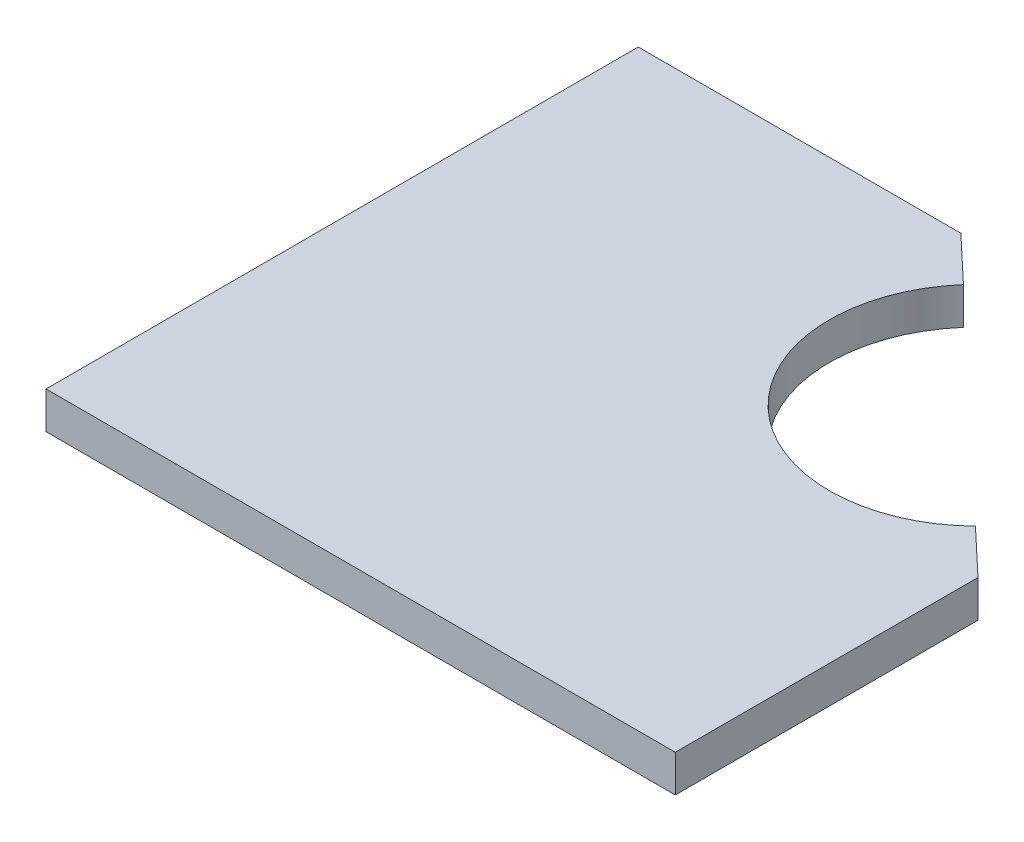
from build123d import *

# Parameters (mm, degrees)
BOSS_EXTRU_1_DEPTH = 5


with BuildPart() as part:
    # Esquisse1 → Boss.-Extru.1 (new body)
    with BuildSketch(Plane(origin=(0, 0, 0), x_dir=(1, 0, 0), z_dir=(0, 1, 0))):
        with BuildLine():
            Line((-42.5, 40), (1.075699519, 40))
            Line((1.075699519, 40), (7.256174968, 34.16461456))
            ThreePointArc((7.256174968, 34.16461456), (8.582181318, 6.457704827), (36.319524552, 6.724031969))
            Line((36.319524552, 6.724031969), (42.5, 0.88864653))
            Line((42.5, 0.88864653), (42.5, -40))
            Line((42.5, -40), (-42.5, -40))
            Line((-42.5, -40), (-42.5, 40))
        make_face()
    extrude(amount=BOSS_EXTRU_1_DEPTH)


solid = part.part
